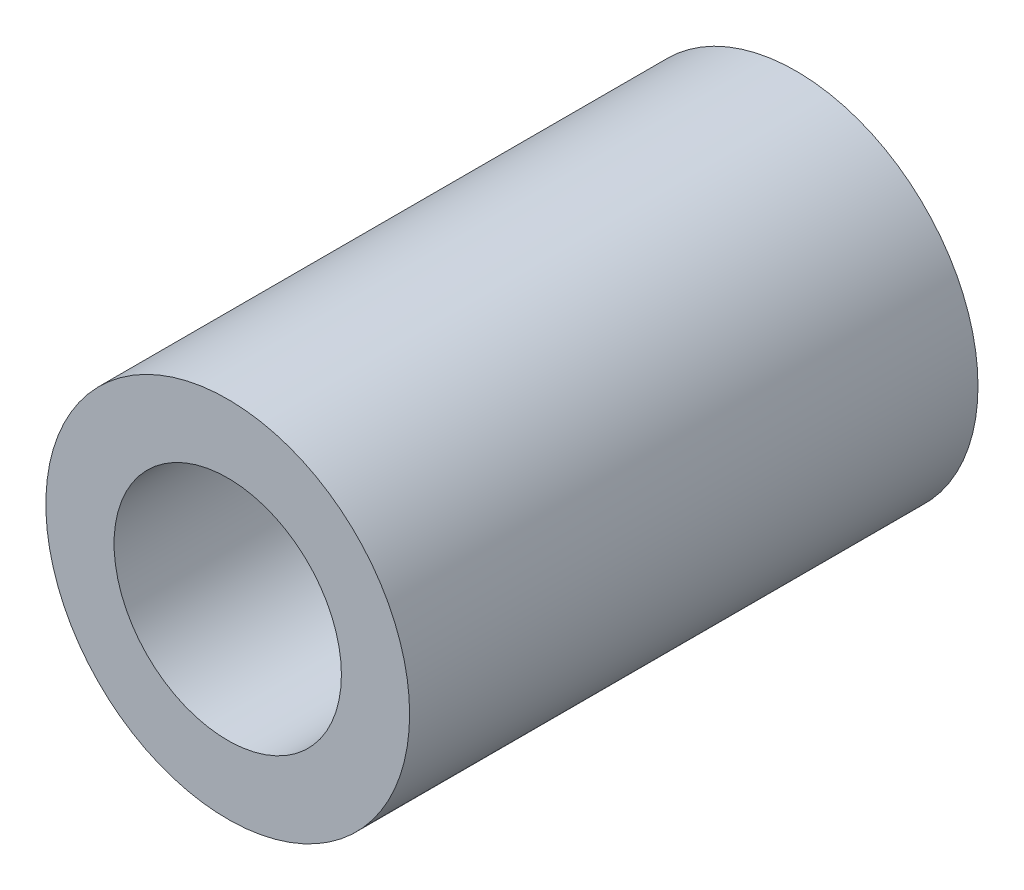
from build123d import *

# Parameters (mm, degrees)
SKETCH1_R           = 8
SKETCH1_R_2         = 5
BOSS_EXTRUDE1_DEPTH = 25


with BuildPart() as part:
    # Sketch1 → Boss-Extrude1 (new body)
    with BuildSketch(Plane.XY):
        with Locations((84.25, 0)):
            Circle(SKETCH1_R)
        with Locations((84.25, 0)):
            Circle(SKETCH1_R_2, mode=Mode.SUBTRACT)
    extrude(amount=BOSS_EXTRUDE1_DEPTH)


solid = part.part
